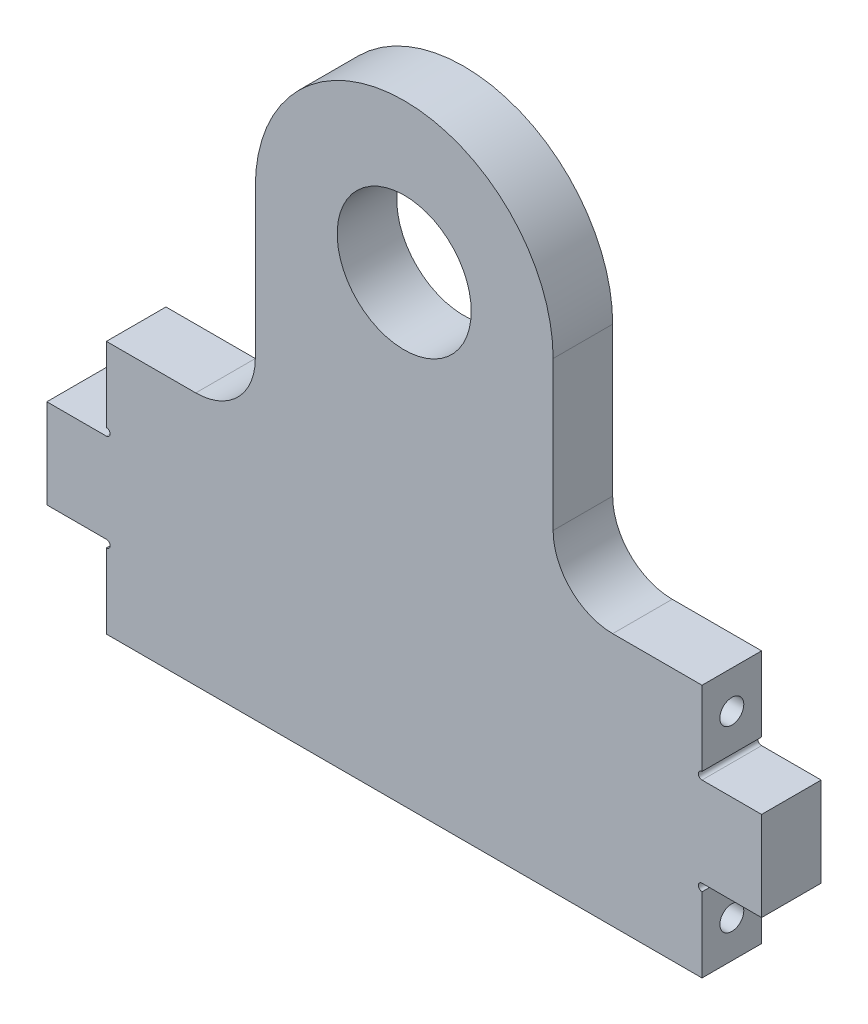
from build123d import *

# Parameters (mm, degrees)
SKETCH1_W                        = 127
SKETCH1_H                        = 152.4
BOSS_EXTRUDE1_DEPTH              = 12.7
SKETCH2_R                        = 14.2875
CUT_EXTRUDE1_DEPTH               = 13.7
FILLET1_R                        = 12.7
SKETCH3_W                        = 127
SKETCH3_H                        = 3.261499881
BOSS_EXTRUDE2_DEPTH              = 12.7
F_1_4_20_TAPPED_HOLE1_AT_2_COUNT = 2
F_1_4_20_TAPPED_HOLE1_AT_2_PITCH = 38.1
SKETCH6_W                        = 12.7
SKETCH6_H                        = 19.05
BOSS_EXTRUDE3_DEPTH              = 12.7
SKETCH7_R                        = 0.79375
CUT_EXTRUDE2_DEPTH               = 13.7


with BuildPart() as part:
    # Sketch1 → Boss-Extrude1 (new body)
    with BuildSketch(Plane.XY):
        with Locations((0, 76.2)):
            Rectangle(SKETCH1_W, SKETCH1_H)
    extrude(amount=BOSS_EXTRUDE1_DEPTH)

    # Sketch2 → Cut-Extrude1 (cut, through all)
    with BuildSketch(Plane.XY.offset(12.7)):
        with Locations((0, 95.25)):
            Circle(SKETCH2_R)
        with BuildLine():
            Line((31.75, 95.25), (31.75, 50.8))
            Line((31.75, 50.8), (63.5, 50.8))
            Line((63.5, 50.8), (63.5, 152.4))
            Line((63.5, 152.4), (-63.5, 152.4))
            Line((-63.5, 152.4), (-63.5, 50.8))
            Line((-63.5, 50.8), (-31.75, 50.8))
            Line((-31.75, 50.8), (-31.75, 95.25))
            ThreePointArc((-31.75, 95.25), (0, 127), (31.75, 95.25))
        make_face()
    extrude(amount=-CUT_EXTRUDE1_DEPTH, mode=Mode.SUBTRACT)

    # Fillet1
    fillet1_edges = [part.edges().sort_by_distance(p)[0] for p in [
        (-31.75, 50.8, 6.35),
        (31.75, 50.8, 6.35),
    ]]
    fillet(fillet1_edges, radius=FILLET1_R)

    # Sketch3 → Boss-Extrude2 (add)
    with BuildSketch(Plane.XY.offset(12.7)):
        with Locations((0, -1.630749941)):
            Rectangle(SKETCH3_W, SKETCH3_H)
    extrude(amount=-BOSS_EXTRUDE2_DEPTH)

    # Sketch4 → 1/4-20 Tapped Hole1 (revolve, cut)
    with BuildSketch(Plane(origin=(63.5, 42.81925006, 6.35), x_dir=(0, 0, -1), z_dir=(0, 1, 0))):
        Polygon((0, 0), (0, 18.043816902), (2.5527, 16.51), (2.5527, 0), align=None)
    f_1_4_20_tapped_hole1 = revolve(axis=Axis((69.85, 42.81925006, 6.35), (-1, 0, 0)), mode=Mode.SUBTRACT)

    # 1/4-20 Tapped Hole1 at 2: 1/4-20 Tapped Hole1 ×2
    with Locations(*[(0, -i * F_1_4_20_TAPPED_HOLE1_AT_2_PITCH, 0) for i in range(1, F_1_4_20_TAPPED_HOLE1_AT_2_COUNT)]):
        add(f_1_4_20_tapped_hole1, mode=Mode.SUBTRACT)

    # Sketch6 → Boss-Extrude3 (add)
    with BuildSketch(Plane(origin=(63.5, 0, 0), x_dir=(0, 0, -1), z_dir=(1, 0, 0))):
        with Locations((-6.35, 23.76925006)):
            Rectangle(SKETCH6_W, SKETCH6_H)
    boss_extrude3 = extrude(amount=BOSS_EXTRUDE3_DEPTH)

    # Sketch7 → Cut-Extrude2 (cut, through all)
    with BuildSketch(Plane.XY.offset(12.7)):
        with Locations((63.5, 34.08800006)):
            Circle(SKETCH7_R)
        with Locations((63.5, 13.45050006)):
            Circle(SKETCH7_R)
    cut_extrude2 = extrude(amount=-CUT_EXTRUDE2_DEPTH, mode=Mode.SUBTRACT)

    # Mirror1: Cut-Extrude2, Boss-Extrude3, 1/4-20 Tapped Hole1 across plane
    add(cut_extrude2.mirror(Plane(origin=(0, 0, 0), x_dir=(0, 0, 1), z_dir=(1, 0, 0))), mode=Mode.SUBTRACT)
    add(boss_extrude3.mirror(Plane(origin=(0, 0, 0), x_dir=(0, 0, 1), z_dir=(1, 0, 0))))
    add(f_1_4_20_tapped_hole1.mirror(Plane(origin=(0, 0, 0), x_dir=(0, 0, 1), z_dir=(1, 0, 0))), mode=Mode.SUBTRACT)

    # Mirror1 copy 1 sketch → Mirror1 copy 1 (revolve, cut)
    with BuildSketch(Plane(origin=(-63.5, 4.71925006, 6.35), x_dir=(0, 0, -1), z_dir=(0, 1, 0))):
        Polygon((0, 0), (0, -18.043816902), (2.5527, -16.51), (2.5527, 0), align=None)
    revolve(axis=Axis((-69.85, 4.71925006, 6.35), (-1, 0, 0)), mode=Mode.SUBTRACT)


solid = part.part
